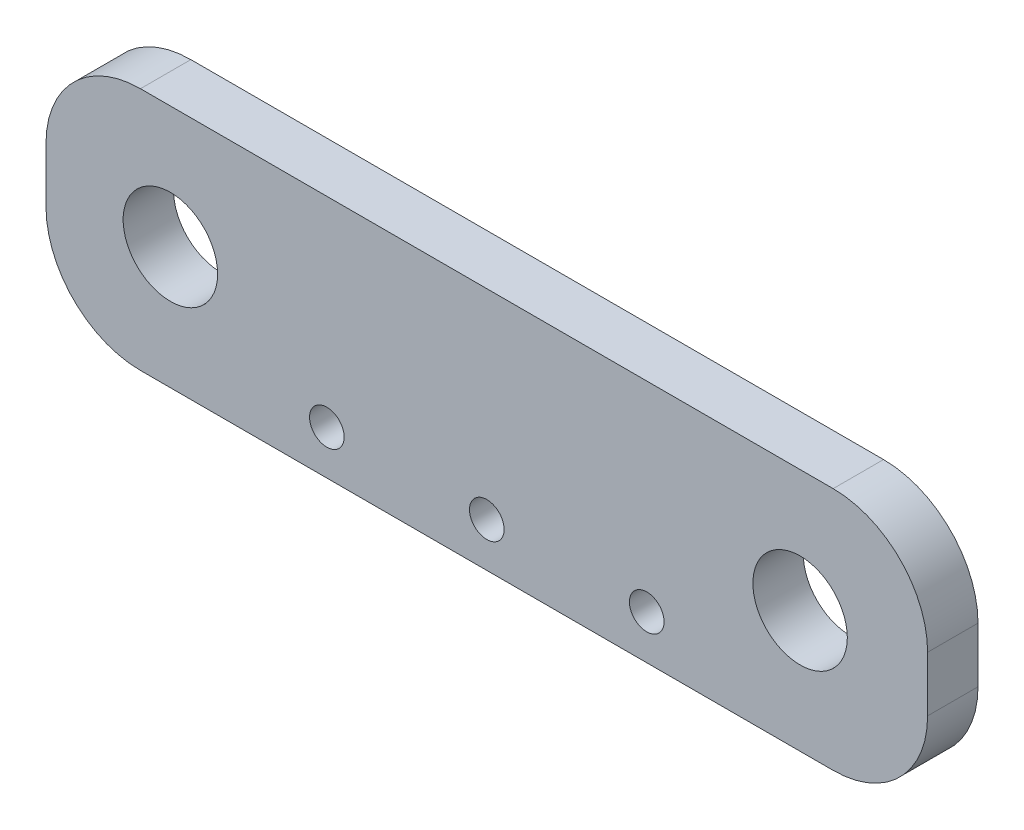
from build123d import *

# Parameters (mm, degrees)
SKETCH1_W           = 28
SKETCH1_H           = 7.75
BOSS_EXTRUDE1_DEPTH = 1.6
SKETCH2_R           = 1.5
CUT_EXTRUDE1_DEPTH  = 2.6
SKETCH3_R           = 0.55
CUT_EXTRUDE2_DEPTH  = 2.6
FILLET1_R           = 3


with BuildPart() as part:
    # Sketch1 → Boss-Extrude1 (new body)
    with BuildSketch(Plane.XY):
        Rectangle(SKETCH1_W, SKETCH1_H)
    extrude(amount=BOSS_EXTRUDE1_DEPTH)

    # Sketch2 → Cut-Extrude1 (cut, through all)
    with BuildSketch(Plane.XY.offset(1.6)):
        with Locations((-10.05, 0)):
            Circle(SKETCH2_R)
        with Locations((9.95, 0)):
            Circle(SKETCH2_R)
    extrude(amount=-CUT_EXTRUDE1_DEPTH, mode=Mode.SUBTRACT)

    # Sketch3 → Cut-Extrude2 (cut, through all)
    with BuildSketch(Plane.XY.offset(1.6)):
        with Locations((0, -2.475)):
            Circle(SKETCH3_R)
        with Locations((-5.08, -2.475)):
            Circle(SKETCH3_R)
        with Locations((5.08, -2.475)):
            Circle(SKETCH3_R)
    extrude(amount=-CUT_EXTRUDE2_DEPTH, mode=Mode.SUBTRACT)

    # Fillet1
    fillet1_edges = [part.edges().sort_by_distance(p)[0] for p in [
        (14, -3.875, 0.8),
        (-14, -3.875, 0.8),
        (-14, 3.875, 0.8),
        (14, 3.875, 0.8),
    ]]
    fillet(fillet1_edges, radius=FILLET1_R)


solid = part.part
